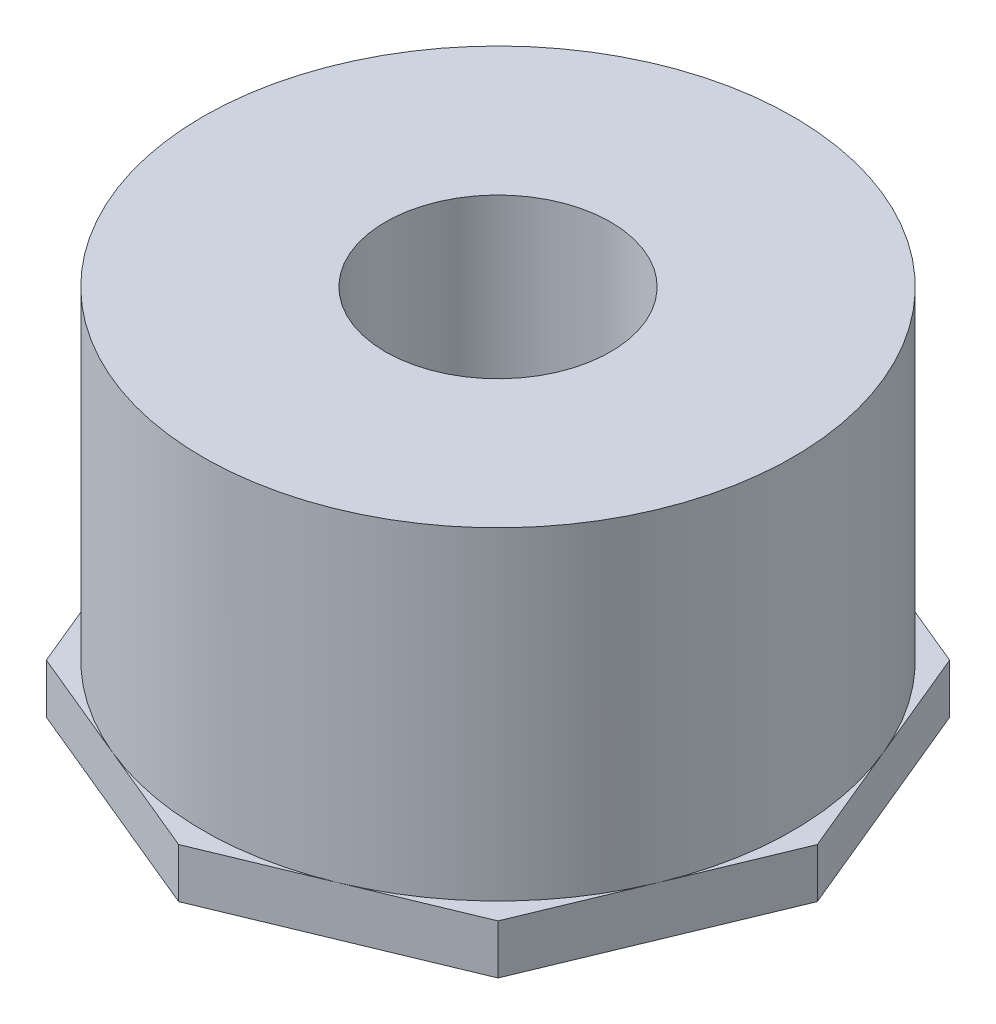
from build123d import *

# Parameters (mm, degrees)
SKETCH1_W           = 30.1625
SKETCH1_H           = 38.1
BOSS_EXTRUDE1_DEPTH = 5.0546


with BuildPart() as part:
    # Sketch1 → Revolve1 (revolve)
    with BuildSketch(Plane.XY):
        with Locations((-15.08125, 19.05)):
            Rectangle(SKETCH1_W, SKETCH1_H)
    revolve(axis=Axis((0, 0, 0), (0, -1, 0)))

    # Sketch2 → Boss-Extrude1 (add)
    with BuildSketch(Plane.XZ):
        Polygon((0, 32.647654741), (-23.085378057, 23.085378057), (-32.647654741, 0), (-23.085378057, -23.085378057), (0, -32.647654741), (23.085378057, -23.085378057), (32.647654741, 0), (23.085378057, 23.085378057), align=None)
    extrude(amount=-BOSS_EXTRUDE1_DEPTH)

    # Sketch4 → 3/4 NPT Tapped Hole1 (revolve, cut)
    with BuildSketch(Plane(origin=(0, 0, 0), x_dir=(0, 0, -1), z_dir=(1, 0, 0))):
        Polygon((0, 0), (0, 38.1), (11.5062, 38.1), (11.5062, 14.05382), (12.137858809, 14.05382), (12.558649, 0), align=None)
    revolve(axis=Axis((0, -6.35, 0), (0, 1, 0)), mode=Mode.SUBTRACT)


solid = part.part
